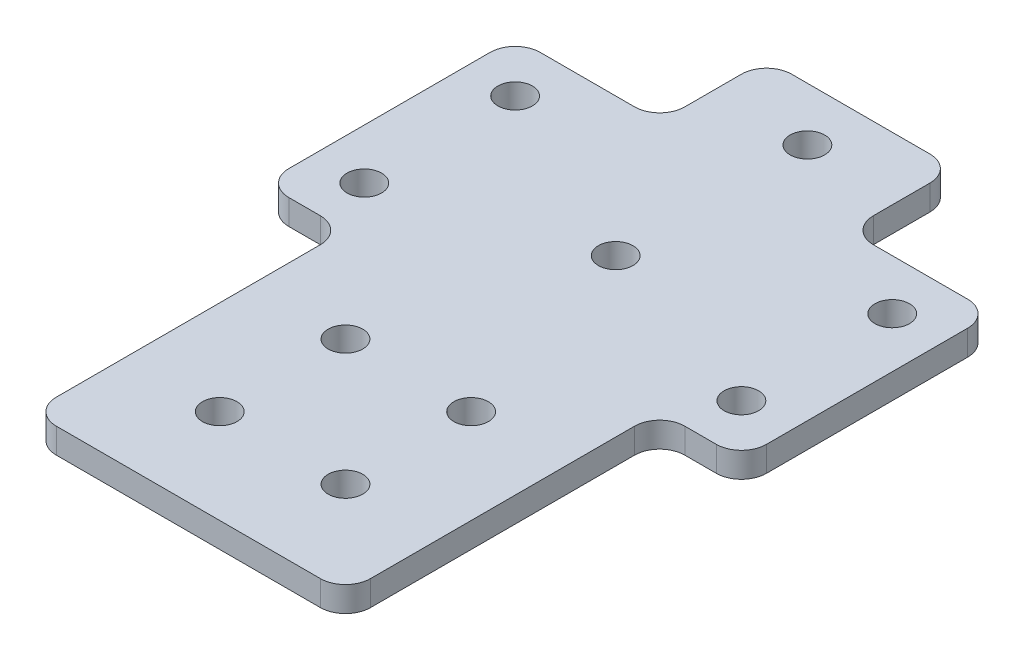
from build123d import *

# Parameters (mm, degrees)
SKETCH1_W           = 76
SKETCH1_H           = 40
SKETCH1_R           = 2.75
BOSS_EXTRUDE1_DEPTH = 4
SKETCH2_W           = 50
SKETCH2_H           = 50
SKETCH2_W_2         = 30
SKETCH2_H_2         = 17
BOSS_EXTRUDE2_DEPTH = 4
SKETCH3_R           = 2.75
CUT_EXTRUDE1_DEPTH  = 4
FILLET1_R           = 4


with BuildPart() as part:
    # Sketch1 → Boss-Extrude1 (new body)
    with BuildSketch(Plane(origin=(0, 0, 0), x_dir=(1, 0, 0), z_dir=(0, 1, 0))):
        with Locations((0, -5)):
            Rectangle(SKETCH1_W, SKETCH1_H)
        with Locations((-30, 7)):
            Circle(SKETCH1_R, mode=Mode.SUBTRACT)
        with Locations((30, 7)):
            Circle(SKETCH1_R, mode=Mode.SUBTRACT)
        with Locations((-30, -17)):
            Circle(SKETCH1_R, mode=Mode.SUBTRACT)
        with Locations((30, -17)):
            Circle(SKETCH1_R, mode=Mode.SUBTRACT)
    extrude(amount=BOSS_EXTRUDE1_DEPTH)

    # Sketch2 → Boss-Extrude2 (add)
    with BuildSketch(Plane(origin=(0, 4, 0), x_dir=(1, 0, 0), z_dir=(0, 1, 0))):
        with Locations((0, -50)):
            Rectangle(SKETCH2_W, SKETCH2_H)
        with Locations((0, 23.5)):
            Rectangle(SKETCH2_W_2, SKETCH2_H_2)
    extrude(amount=-BOSS_EXTRUDE2_DEPTH)

    # Sketch3 → Cut-Extrude1 (cut)
    with BuildSketch(Plane(origin=(0, 4, 0), x_dir=(1, 0, 0), z_dir=(0, 1, 0))):
        with Locations((0, 23.5)):
            Circle(SKETCH3_R)
        with Locations((0, -7)):
            Circle(SKETCH3_R)
        with Locations((-10, -40)):
            Circle(SKETCH3_R)
        with Locations((10, -40)):
            Circle(SKETCH3_R)
        with Locations((-10, -60)):
            Circle(SKETCH3_R)
        with Locations((10, -60)):
            Circle(SKETCH3_R)
    extrude(amount=-CUT_EXTRUDE1_DEPTH, mode=Mode.SUBTRACT)

    # Fillet1
    fillet1_edges = [part.edges().sort_by_distance(p)[0] for p in [
        (-25, 2, 75),
        (25, 2, 75),
        (25, 2, 25),
        (38, 2, 25),
        (38, 2, -15),
        (-38, 2, -15),
        (-38, 2, 25),
        (-25, 2, 25),
        (15, 2, -15),
        (15, 2, -32),
        (-15, 2, -32),
        (-15, 2, -15),
    ]]
    fillet(fillet1_edges, radius=FILLET1_R)


solid = part.part
